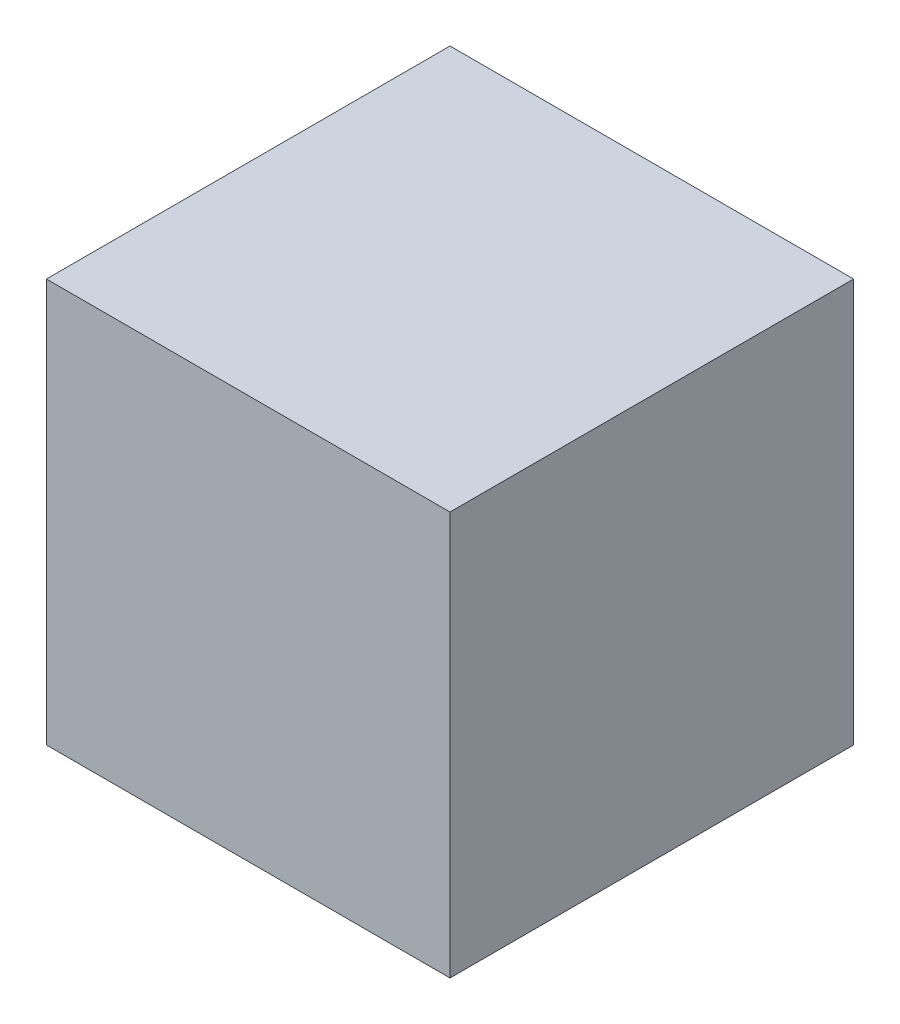
from build123d import *

# Parameters (mm, degrees)
BOSS_EXTRUDE1_DEPTH      = 5
BOSS_EXTRUDE1_DEPTH_BACK = 5
SKETCH1_W                = 10
SKETCH1_H                = 10


with BuildPart() as part:
    # Sketch1 → Boss-Extrude1 (new, two sides: drawn at the far end of the back side and taken through both)
    with BuildSketch(Plane(origin=(0, 0, 0), x_dir=(1, 0, 0), z_dir=(0, 1, 0)).offset(-BOSS_EXTRUDE1_DEPTH_BACK)):
        Rectangle(SKETCH1_W, SKETCH1_H)
    extrude(amount=BOSS_EXTRUDE1_DEPTH + BOSS_EXTRUDE1_DEPTH_BACK)


solid = part.part
